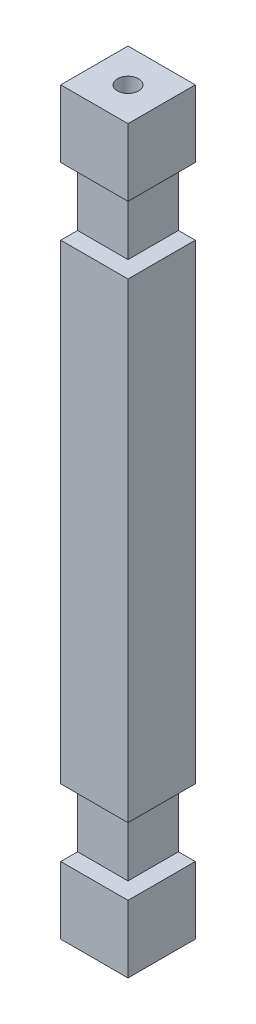
from build123d import *

# Parameters (mm, degrees)
SKETCH2_W           = 50.8
SKETCH2_H           = 558.8
BOSS_EXTRUDE1_DEPTH = 50.8
SKETCH5_W           = 50.8
SKETCH5_H           = 50.8
CUT_EXTRUDE1_DEPTH  = 12.7
SKETCH6_W           = 50.8
SKETCH6_H           = 50.8
CUT_EXTRUDE2_DEPTH  = 12.7
SKETCH10_W          = 50.8
SKETCH10_H          = 50.8
CUT_EXTRUDE3_DEPTH  = 12.7
SKETCH11_W          = 50.8
SKETCH11_H          = 50.8
CUT_EXTRUDE4_DEPTH  = 12.7
SKETCH12_R          = 8
CUT_EXTRUDE5_DEPTH  = 16
SKETCH13_R          = 8
CUT_EXTRUDE6_DEPTH  = 16


with BuildPart() as part:
    # Sketch2 → Boss-Extrude1 (new body)
    with BuildSketch(Plane.XY):
        Rectangle(SKETCH2_W, SKETCH2_H)
    extrude(amount=BOSS_EXTRUDE1_DEPTH)

    # Sketch5 → Cut-Extrude1 (cut)
    with BuildSketch(Plane.XY.offset(50.8)):
        with Locations((0, 203.2)):
            Rectangle(SKETCH5_W, SKETCH5_H)
    extrude(amount=-CUT_EXTRUDE1_DEPTH, mode=Mode.SUBTRACT)

    # Sketch6 → Cut-Extrude2 (cut)
    with BuildSketch(Plane(origin=(25.4, 0, 0), x_dir=(0, 0, -1), z_dir=(1, 0, 0))):
        with Locations((-25.4, 203.2)):
            Rectangle(SKETCH6_W, SKETCH6_H)
    extrude(amount=-CUT_EXTRUDE2_DEPTH, mode=Mode.SUBTRACT)

    # Sketch10 → Cut-Extrude3 (cut)
    with BuildSketch(Plane.XY.offset(50.8)):
        with Locations((0, -203.2)):
            Rectangle(SKETCH10_W, SKETCH10_H)
    extrude(amount=-CUT_EXTRUDE3_DEPTH, mode=Mode.SUBTRACT)

    # Sketch11 → Cut-Extrude4 (cut)
    with BuildSketch(Plane(origin=(25.4, 0, 0), x_dir=(0, 0, -1), z_dir=(1, 0, 0))):
        with Locations((-25.4, -203.2)):
            Rectangle(SKETCH11_W, SKETCH11_H)
    extrude(amount=-CUT_EXTRUDE4_DEPTH, mode=Mode.SUBTRACT)

    # Sketch12 → Cut-Extrude5 (cut)
    with BuildSketch(Plane.XZ.offset(279.4)):
        with Locations((0, 25.4)):
            Circle(SKETCH12_R)
    extrude(amount=-CUT_EXTRUDE5_DEPTH, mode=Mode.SUBTRACT)

    # Sketch13 → Cut-Extrude6 (cut)
    with BuildSketch(Plane(origin=(0, 279.4, 0), x_dir=(1, 0, 0), z_dir=(0, 1, 0))):
        with Locations((0, -25.4)):
            Circle(SKETCH13_R)
    extrude(amount=-CUT_EXTRUDE6_DEPTH, mode=Mode.SUBTRACT)


solid = part.part
